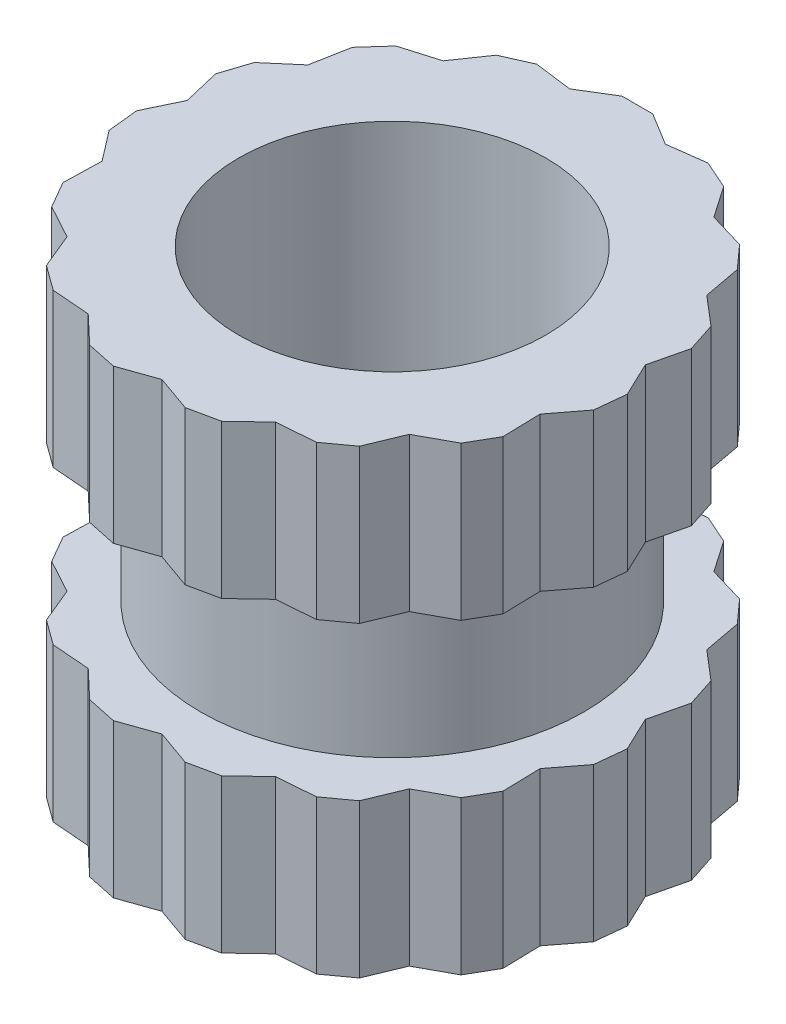
from build123d import *

# Parameters (mm, degrees)
SKETCH1_R           = 1.25
SKETCH1_R_2         = 1
BOSS_EXTRUDE1_DEPTH = 1.5
SKETCH2_R           = 1
BOSS_EXTRUDE2_DEPTH = 1


with BuildPart() as part:
    # Sketch1 → Boss-Extrude1 (new body)
    with BuildSketch(Plane(origin=(0, 0, 0), x_dir=(1, 0, 0), z_dir=(0, 1, 0))):
        Circle(SKETCH1_R)
        Circle(SKETCH1_R_2, mode=Mode.SUBTRACT)
    boss_extrude1 = extrude(amount=BOSS_EXTRUDE1_DEPTH)

    # Sketch2 → Boss-Extrude2 (add)
    with BuildSketch(Plane(origin=(0, 1.5, 0), x_dir=(1, 0, 0), z_dir=(0, 1, 0))):
        Polygon((-0.740860879, 1.418141445), (-0.881677878, 1.213525492), (-1.11979406, 1.142830374), (-1.253620181, 0.994201408), (-1.299038106, 0.75), (-1.487813767, 0.58856622), (-1.549617166, 0.398354916), (-1.491782843, 0.156792695), (-1.598576957, -0.067466381), (-1.577671264, -0.26637076), (-1.426584774, -0.463525492), (-1.432931669, -0.711833431), (-1.332931669, -0.885038512), (-1.114717238, -1.00369591), (-1.019519477, -1.233118014), (-0.857716078, -1.350675064), (-0.610104965, -1.370318186), (-0.429823106, -1.54118529), (-0.234193585, -1.582767628), (0, -1.5), (0.234193585, -1.582767628), (0.429823106, -1.54118529), (0.610104965, -1.370318186), (0.857716078, -1.350675064), (1.019519477, -1.233118014), (1.114717238, -1.00369591), (1.332931669, -0.885038512), (1.432931669, -0.711833431), (1.426584774, -0.463525492), (1.577671264, -0.26637076), (1.598576957, -0.067466381), (1.491782843, 0.156792695), (1.549617166, 0.398354916), (1.487813767, 0.58856622), (1.299038106, 0.75), (1.253620181, 0.994201408), (1.11979406, 1.142830374), (0.881677878, 1.213525492), (0.740860879, 1.418141445), (0.558151787, 1.499488774), (0.311867536, 1.467221401), (0.1, 1.596871942), (-0.1, 1.596871942), (-0.311867536, 1.467221401), (-0.558151787, 1.499488774), align=None)
        Circle(SKETCH2_R, mode=Mode.SUBTRACT)
    boss_extrude2 = extrude(amount=-BOSS_EXTRUDE2_DEPTH)

    # Mirror1: Boss-Extrude1, Boss-Extrude2 across plane
    add(boss_extrude1.mirror(Plane.ZX))
    add(boss_extrude2.mirror(Plane.ZX))


solid = part.part
